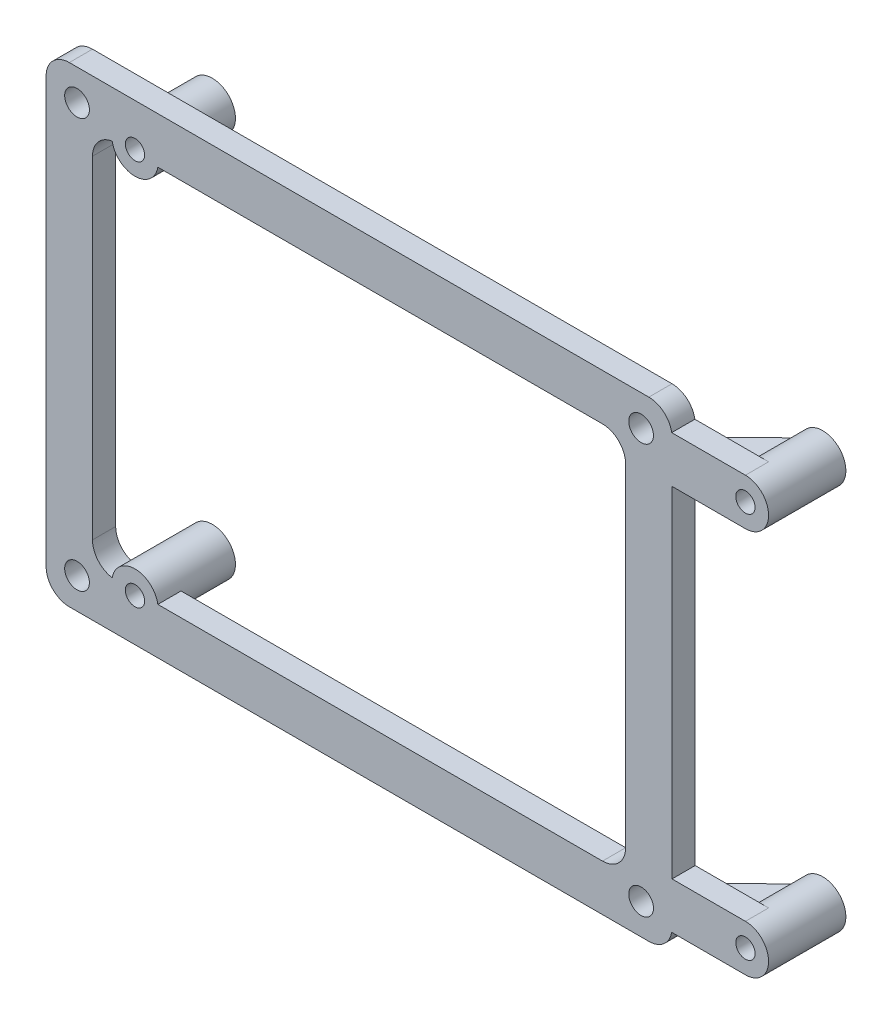
from build123d import *

# Parameters (mm, degrees)
SKETCH1_W           = 81
SKETCH1_H           = 61
SKETCH1_W_2         = 69
SKETCH1_H_2         = 49
EXTRUDE_THIN1_DEPTH = 3
SKETCH2_R           = 1.6
CUT_EXTRUDE1_DEPTH  = 3
FILLET1_R           = 3
SKETCH4_R           = 3
BOSS_EXTRUDE1_DEPTH = 10
BOSS_EXTRUDE2_DEPTH = 3
SKETCH5_R           = 1.25
CUT_EXTRUDE2_DEPTH  = 10
RIB2_REACH          = 79.06
SKETCH7_WALL_W      = 166.153683654
SKETCH7_WALL_H      = 2
LPATTERN1_COUNT     = 2
LPATTERN1_PITCH     = 50


with BuildPart() as part:
    # Sketch1 → Extrude-Thin1 (new body)
    with BuildSketch(Plane.XY):
        Rectangle(SKETCH1_W, SKETCH1_H)
        Rectangle(SKETCH1_W_2, SKETCH1_H_2, mode=Mode.SUBTRACT)
    extrude(amount=EXTRUDE_THIN1_DEPTH)

    # Sketch2 → Cut-Extrude1 (cut)
    with BuildSketch(Plane.XY.offset(3)):
        with Locations((-36.5, 26.5)):
            Circle(SKETCH2_R)
        with Locations((36.5, 26.5)):
            Circle(SKETCH2_R)
        with Locations((36.5, -26.5)):
            Circle(SKETCH2_R)
        with Locations((-36.5, -26.5)):
            Circle(SKETCH2_R)
    extrude(amount=-CUT_EXTRUDE1_DEPTH, mode=Mode.SUBTRACT)

    # Fillet1
    fillet1_edges = [part.edges().sort_by_distance(p)[0] for p in [
        (-34.5, 24.5, 1.5),
        (-34.5, -24.5, 1.5),
        (34.5, -24.5, 1.5),
        (34.5, 24.5, 1.5),
        (-40.5, 30.5, 1.5),
        (40.5, 30.5, 1.5),
        (40.5, -30.5, 1.5),
        (-40.5, -30.5, 1.5),
    ]]
    fillet(fillet1_edges, radius=FILLET1_R)

    # Sketch4 → Boss-Extrude1 (add)
    with BuildSketch(Plane.XY.offset(3)):
        with Locations((-29, 25)):
            Circle(SKETCH4_R)
        with Locations((50, 25)):
            Circle(SKETCH4_R)
        with Locations((50, -25)):
            Circle(SKETCH4_R)
        with Locations((-29, -25)):
            Circle(SKETCH4_R)
    extrude(amount=-BOSS_EXTRUDE1_DEPTH)


with BuildPart() as boss_extrude1_piece_1:
    # of the separate pieces the step leaves, piece 1, a body of its own (boss_extrude1_pieces)
    add(part.part.solids().sort_by_distance((-37.5, -30.5, 0))[0])



with BuildPart() as boss_extrude1_piece_2:
    # of the separate pieces the step leaves, piece 2, a body of its own (boss_extrude1_pieces)
    add(part.part.solids().sort_by_distance((53, 25, 3))[0])


with BuildPart() as boss_extrude1_piece_3:
    # of the separate pieces the step leaves, piece 3, a body of its own (boss_extrude1_pieces)
    add(part.part.solids().sort_by_distance((53, -25, 3))[0])


with BuildPart() as boss_extrude1_piece_1_1:
    add(boss_extrude1_piece_1.part)

    add(boss_extrude1_piece_2.part)  # Boss-Extrude2 merges Boss-Extrude1 piece 2

    add(boss_extrude1_piece_3.part)  # Boss-Extrude2 merges Boss-Extrude1 piece 3
    # Sketch6 → Boss-Extrude2 (add)
    with BuildSketch(Plane.XY.offset(3)):
        with BuildLine():
            Line((50, 28), (40.458039892, 28))
            Line((40.458039892, 28), (40.5, 22))
            Line((40.5, 22), (50, 22))
            ThreePointArc((50, 22), (53, 25), (50, 28))
        make_face()
        with BuildLine():
            Line((40.5, -22), (40.458039892, -28))
            Line((40.458039892, -28), (50, -28))
            ThreePointArc((50, -28), (53, -25), (50, -22))
            Line((50, -22), (40.5, -22))
        make_face()
    extrude(amount=-BOSS_EXTRUDE2_DEPTH)

    # Sketch5 → Cut-Extrude2 (cut)
    with BuildSketch(Plane(origin=(0, 0, -7), x_dir=(-1, 0, 0), z_dir=(0, 0, -1))):
        with Locations((-50, 25)):
            Circle(SKETCH5_R)
        with Locations((29, 25)):
            Circle(SKETCH5_R)
        with Locations((-50, -25)):
            Circle(SKETCH5_R)
        with Locations((29, -25)):
            Circle(SKETCH5_R)
    extrude(amount=-CUT_EXTRUDE2_DEPTH, mode=Mode.SUBTRACT)

    # Sketch7 wall → Rib2 (add, up to next)
    with BuildSketch(Plane(origin=(44.051757722, 25, -3.500496738), x_dir=(-0.716336631923, 0, 0.697754849331), z_dir=(0.697754849331, 0, 0.716336631923)), mode=Mode.PRIVATE) as rib2_sk1:
        Rectangle(SKETCH7_WALL_W, SKETCH7_WALL_H)
    rib2_tool1 = extrude(rib2_sk1.sketch, amount=RIB2_REACH, mode=Mode.PRIVATE) - boss_extrude1_piece_1_1.part
    rib2 = rib2_tool1.solids().sort_by_distance((44.051757722, 25, -3.500496738))[0]
    add(rib2)

    # LPattern1: Rib2 ×2
    with Locations(*[(0, -i * LPATTERN1_PITCH, 0) for i in range(1, LPATTERN1_COUNT)]):
        add(rib2)


solid = boss_extrude1_piece_1_1.part
